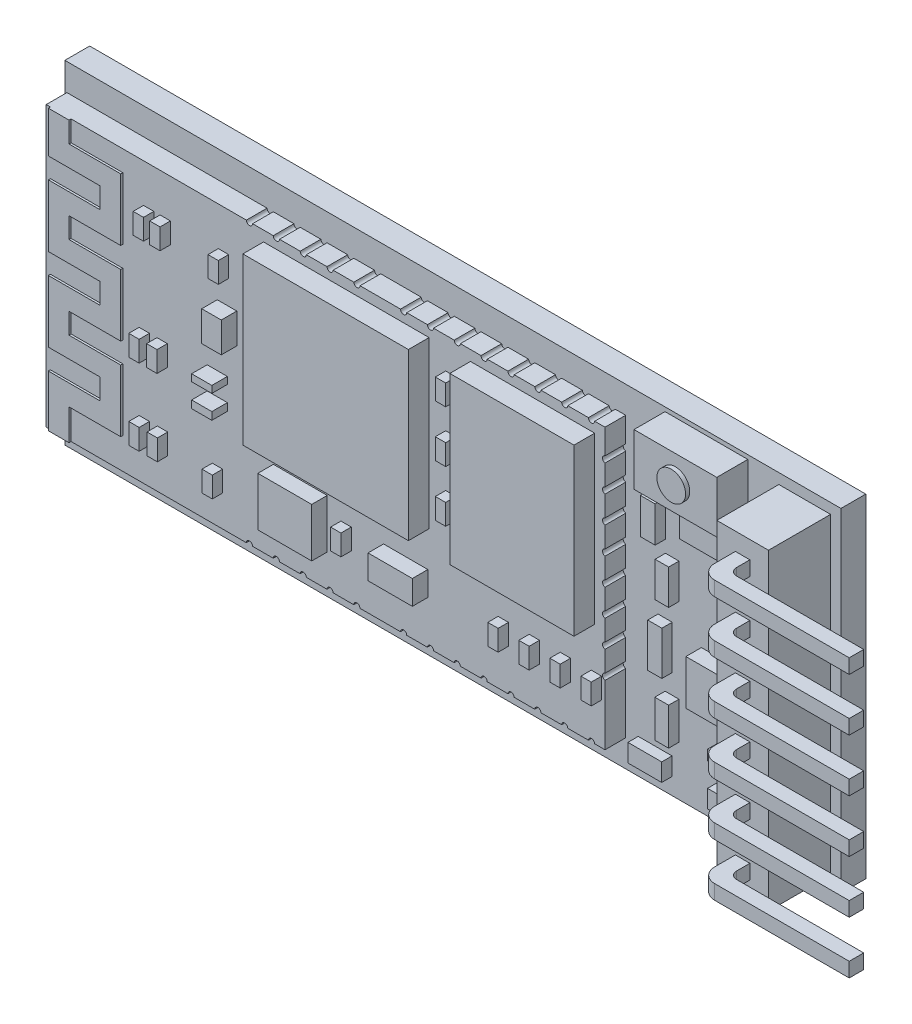
from build123d import *

# Parameters (mm, degrees)
IZIM2_W                      = 37.5
IZIM2_H                      = 16.1
Y_KSEKLIK_EKSTR_ZYON1_DEPTH  = 1.2
IZIM5_W                      = 2.5
IZIM5_H                      = 15.1
Y_KSEKLIK_EKSTR_ZYON2_DEPTH  = 3
IZIM14_W                     = 27
IZIM14_H                     = 13.5
Y_KSEKLIK_EKSTR_ZYON10_DEPTH = 1
Y_KSEKLIK_EKSTR_ZYON11_DEPTH = 0.1
IZIM16_W                     = 4
IZIM16_H                     = 2.5
Y_KSEKLIK_EKSTR_ZYON12_DEPTH = 1.5
IZIM17_R                     = 0.693604575
Y_KSEKLIK_EKSTR_ZYON13_DEPTH = 0.2
IZIM18_W                     = 6
IZIM18_H                     = 8
IZIM18_W_2                   = 8
Y_KSEKLIK_EKSTR_ZYON14_DEPTH = 1
IZIM19_W                     = 0.5
IZIM19_H                     = 1
Y_KSEKLIK_EKSTR_ZYON15_DEPTH = 0.5
IZIM22_W                     = 0.5
IZIM22_H                     = 1
Y_KSEKLIK_EKSTR_ZYON17_DEPTH = 0.5
IZIM23_W                     = 2.602430281
IZIM23_H                     = 2.367545487
IZIM23_W_2                   = 2.141321068
IZIM23_H_2                   = 1.16646021
IZIM23_W_3                   = 0.976073465
IZIM23_H_3                   = 0.365909355
IZIM23_H_4                   = 0.334632026
IZIM23_W_4                   = 0.943360629
IZIM23_H_5                   = 1.46024084
Y_KSEKLIK_EKSTR_ZYON18_DEPTH = 0.75
IZIM24_W                     = 2.706810909
IZIM24_H                     = 1.742911909
IZIM24_W_2                   = 0.716474489
IZIM24_H_2                   = 1.726632447
IZIM24_W_3                   = 0.652791749
IZIM24_H_3                   = 1.693765047
IZIM24_W_4                   = 0.684633119
IZIM24_H_4                   = 2.106353334
IZIM24_W_5                   = 0.668712434
IZIM24_H_5                   = 1.80079444
IZIM24_W_6                   = 1.634021616
IZIM24_H_6                   = 0.862411809
IZIM24_W_7                   = 1.353405455
IZIM24_H_7                   = 0.499412084
IZIM24_W_8                   = 1.368285393
IZIM24_H_8                   = 0.823617913
IZIM24_H_9                   = 0.791721171
Y_KSEKLIK_EKSTR_ZYON19_DEPTH = 0.5
IZIM25_W                     = 3.051168615
IZIM25_H                     = 2.165639046
Y_KSEKLIK_EKSTR_ZYON20_DEPTH = 0.75
KES_EKSTR_ZYON1_DEPTH        = 1
KES_EKSTR_ZYON2_DEPTH        = 1
SKETCH1_W                    = 0.7
SKETCH1_H                    = 0.7
BOSS_EXTRUDE1_DEPTH          = 1.7
SKETCH2_W                    = 0.7
SKETCH2_H                    = 0.7
BOSS_EXTRUDE2_DEPTH          = 6.5
FILLET1_R                    = 0.7
FILLET2_R                    = 0.35


with BuildPart() as part:
    # Çizim2 → Yükseklik-Ekstrüzyon1 (new body)
    with BuildSketch(Plane.XY):
        with Locations((18.75, 8.05)):
            Rectangle(IZIM2_W, IZIM2_H)
    extrude(amount=Y_KSEKLIK_EKSTR_ZYON1_DEPTH)

    # Çizim5 → Yükseklik-Ekstrüzyon2 (add)
    with BuildSketch(Plane.XY.offset(1.2)):
        with Locations((35.75, 8.05)):
            Rectangle(IZIM5_W, IZIM5_H)
    extrude(amount=Y_KSEKLIK_EKSTR_ZYON2_DEPTH)

    # Çizim14 → Yükseklik-Ekstrüzyon10 (add)
    with BuildSketch(Plane.XY.offset(1.2)):
        with Locations((13.6, 8.05)):
            Rectangle(IZIM14_W, IZIM14_H)
    extrude(amount=Y_KSEKLIK_EKSTR_ZYON10_DEPTH)

    # Çizim15 → Yükseklik-Ekstrüzyon11 (add)
    with BuildSketch(Plane.XY.offset(2.2)):
        Polygon((0.3, 1.3), (0.3, 3.8), (2.8, 3.8), (2.8, 4.8), (0.3, 4.8), (0.3, 7.8), (2.8, 7.8), (2.8, 8.8), (0.3, 8.8), (0.3, 11.8), (2.8, 11.8), (2.8, 12.8), (0.3, 12.8), (0.3, 14.8), (1.3, 14.8), (1.3, 13.8), (3.8, 13.8), (3.8, 10.8), (1.3, 10.8), (1.3, 9.8), (3.8, 9.8), (3.8, 6.8), (1.3, 6.8), (1.3, 5.8), (3.8, 5.8), (3.8, 2.8), (1.3, 2.8), (1.3, 1.3), align=None)
    extrude(amount=Y_KSEKLIK_EKSTR_ZYON11_DEPTH)



with BuildPart() as body_2:
    # Çizim16 → Yükseklik-Ekstrüzyon12 (new body)
    with BuildSketch(Plane.XY.offset(1.2)):
        with Locations((31, 14.65)):
            Rectangle(IZIM16_W, IZIM16_H)
    extrude(amount=Y_KSEKLIK_EKSTR_ZYON12_DEPTH)


with BuildPart() as part_1:
    add(part.part)

    add(body_2.part)  # Yükseklik-Ekstrüzyon13 merges body 2
    # Çizim17 → Yükseklik-Ekstrüzyon13 (add)
    with BuildSketch(Plane.XY.offset(2.7)):
        with Locations((31, 14.65)):
            Circle(IZIM17_R)
    extrude(amount=Y_KSEKLIK_EKSTR_ZYON13_DEPTH)

    # Çizim18 → Yükseklik-Ekstrüzyon14 (add)
    with BuildSketch(Plane.XY.offset(2.2)):
        with Locations((23.600429337, 10.3)):
            Rectangle(IZIM18_W, IZIM18_H)
        with Locations((14.600429337, 10.3)):
            Rectangle(IZIM18_W_2, IZIM18_H)
    extrude(amount=Y_KSEKLIK_EKSTR_ZYON14_DEPTH)

    # Çizim19 → Yükseklik-Ekstrüzyon15 (add)
    with BuildSketch(Plane.XY.offset(2.2)):
        with Locations((5.05, 12.430030241)):
            Rectangle(IZIM19_W, IZIM19_H)
        with Locations((5.85, 12.430030241)):
            Rectangle(IZIM19_W, IZIM19_H)
        with Locations((8.665669621, 12.430030241)):
            Rectangle(IZIM19_W, IZIM19_H)
    extrude(amount=Y_KSEKLIK_EKSTR_ZYON15_DEPTH)

    # Çizim22 → Yükseklik-Ekstrüzyon17 (add)
    with BuildSketch(Plane.XY.offset(2.2)):
        with Locations((4.838962256, 7.221997086)):
            Rectangle(IZIM22_W, IZIM22_H)
        with Locations((5.701638758, 7.221997086)):
            Rectangle(IZIM22_W, IZIM22_H)
        with Locations((4.838818901, 3.533540421)):
            Rectangle(IZIM22_W, IZIM22_H)
        with Locations((5.720100061, 3.533540421)):
            Rectangle(IZIM22_W, IZIM22_H)
        with Locations((8.374321984, 3.306212795)):
            Rectangle(IZIM22_W, IZIM22_H)
        with Locations((19.650429337, 12.8)):
            Rectangle(IZIM22_W, IZIM22_H)
        with Locations((19.650429337, 10.3)):
            Rectangle(IZIM22_W, IZIM22_H)
        with Locations((19.650429337, 7.8)):
            Rectangle(IZIM22_W, IZIM22_H)
        with Locations((26.685091813, 3.8)):
            Rectangle(IZIM22_W, IZIM22_H)
        with Locations((25.185091813, 3.8)):
            Rectangle(IZIM22_W, IZIM22_H)
        with Locations((23.685091813, 3.8)):
            Rectangle(IZIM22_W, IZIM22_H)
        with Locations((22.185091813, 3.8)):
            Rectangle(IZIM22_W, IZIM22_H)
        with Locations((14.590448244, 3.990810695)):
            Rectangle(IZIM22_W, IZIM22_H)
    extrude(amount=Y_KSEKLIK_EKSTR_ZYON17_DEPTH)

    # Çizim23 → Yükseklik-Ekstrüzyon18 (add)
    with BuildSketch(Plane.XY.offset(2.2)):
        with Locations((12.376318164, 4.047967675)):
            Rectangle(IZIM23_W, IZIM23_H)
        with Locations((17.469520012, 3.979476737)):
            Rectangle(IZIM23_W_2, IZIM23_H_2)
        with Locations((8.364147087, 6.520171395)):
            Rectangle(IZIM23_W_3, IZIM23_H_3)
        with Locations((8.364147087, 7.631045899)):
            Rectangle(IZIM23_W_3, IZIM23_H_4)
        with Locations((8.835827401, 10.033036523)):
            Rectangle(IZIM23_W_4, IZIM23_H_5)
    extrude(amount=Y_KSEKLIK_EKSTR_ZYON18_DEPTH)

    # Çizim24 → Yükseklik-Ekstrüzyon19 (add)
    with BuildSketch(Plane.XY.offset(1.2)):
        with Locations((31.553494099, 12.29905928)):
            Rectangle(IZIM24_W, IZIM24_H)
        with Locations((28.662605916, 11.435743057)):
            Rectangle(IZIM24_W_2, IZIM24_H_2)
        with Locations((29.347239034, 9.137191125)):
            Rectangle(IZIM24_W_3, IZIM24_H_3)
        with Locations((29.004922476, 6.207999371)):
            Rectangle(IZIM24_W_4, IZIM24_H_4)
        with Locations((29.339278692, 3.303381049)):
            Rectangle(IZIM24_W_5, IZIM24_H_5)
        with Locations((28.522267884, 1.231924795)):
            Rectangle(IZIM24_W_6, IZIM24_H_6)
        with Locations((32.230196826, 1.231924795)):
            Rectangle(IZIM24_W_7, IZIM24_H_6)
        with Locations((32.230196826, 3.053675007)):
            Rectangle(IZIM24_W_7, IZIM24_H_7)
        with Locations((32.704361967, 10.395882605)):
            Rectangle(IZIM24_W_8, IZIM24_H_8)
        with Locations((32.704361967, 8.686169187)):
            Rectangle(IZIM24_W_8, IZIM24_H_9)
    extrude(amount=Y_KSEKLIK_EKSTR_ZYON19_DEPTH)

    # Çizim25 → Yükseklik-Ekstrüzyon20 (add)
    with BuildSketch(Plane.XY.offset(1.2)):
        with Locations((32.282514113, 5.823350592)):
            Rectangle(IZIM25_W, IZIM25_H)
    extrude(amount=Y_KSEKLIK_EKSTR_ZYON20_DEPTH)

    # Çizim27 → Kes-Ekstrüzyon1 (cut)
    with BuildSketch(Plane.XY.offset(2.2)):
        with BuildLine():
            Line((26.6, 14.8), (26.3, 14.8))
            ThreePointArc((26.3, 14.8), (26.45, 14.65), (26.6, 14.8))
        make_face()
        with BuildLine():
            Line((25.3, 14.8), (25.004468137, 14.8))
            ThreePointArc((25.004468137, 14.8), (25.152234068, 14.652234068), (25.3, 14.8))
        make_face()
        with BuildLine():
            Line((23.708936273, 14.8), (24.004468137, 14.8))
            ThreePointArc((24.004468137, 14.8), (23.856702205, 14.652234068), (23.708936273, 14.8))
        make_face()
        with BuildLine():
            Line((22.408936273, 14.8), (22.708936273, 14.8))
            ThreePointArc((22.708936273, 14.8), (22.558936273, 14.65), (22.408936273, 14.8))
        make_face()
        with BuildLine():
            Line((21.408936273, 14.8), (21.108936273, 14.8))
            ThreePointArc((21.108936273, 14.8), (21.258936273, 14.65), (21.408936273, 14.8))
        make_face()
        with BuildLine():
            Line((20.108936273, 14.8), (19.81340441, 14.8))
            ThreePointArc((19.81340441, 14.8), (19.961170341, 14.652234068), (20.108936273, 14.8))
        make_face()
        with BuildLine():
            Line((18.517872546, 14.8), (18.81340441, 14.8))
            ThreePointArc((18.81340441, 14.8), (18.665638478, 14.652234068), (18.517872546, 14.8))
        make_face()
        with BuildLine():
            Line((17.217872546, 14.8), (17.517872546, 14.8))
            ThreePointArc((17.517872546, 14.8), (17.367872546, 14.65), (17.217872546, 14.8))
        make_face()
        with BuildLine():
            Line((15.261871651, 14.8), (14.961871651, 14.8))
            ThreePointArc((14.961871651, 14.8), (15.111871651, 14.65), (15.261871651, 14.8))
        make_face()
        with BuildLine():
            Line((13.961871651, 14.8), (13.666339787, 14.8))
            ThreePointArc((13.666339787, 14.8), (13.814105719, 14.652234068), (13.961871651, 14.8))
        make_face()
        with BuildLine():
            Line((12.370807924, 14.8), (12.666339787, 14.8))
            ThreePointArc((12.666339787, 14.8), (12.518573856, 14.652234068), (12.370807924, 14.8))
        make_face()
        with BuildLine():
            Line((11.070807924, 14.8), (11.370807924, 14.8))
            ThreePointArc((11.370807924, 14.8), (11.220807924, 14.65), (11.070807924, 14.8))
        make_face()
        with BuildLine():
            Line((10.070807924, 14.8), (9.770807924, 14.8))
            ThreePointArc((9.770807924, 14.8), (9.920807924, 14.65), (10.070807924, 14.8))
        make_face()
        with BuildLine():
            Line((10.070807924, 1.3), (9.770807924, 1.3))
            ThreePointArc((9.770807924, 1.3), (9.920807924, 1.45), (10.070807924, 1.3))
        make_face()
        with BuildLine():
            Line((11.070807924, 1.3), (11.370807924, 1.3))
            ThreePointArc((11.370807924, 1.3), (11.220807924, 1.45), (11.070807924, 1.3))
        make_face()
        with BuildLine():
            Line((12.370807924, 1.3), (12.666339787, 1.3))
            ThreePointArc((12.666339787, 1.3), (12.518573856, 1.447765932), (12.370807924, 1.3))
        make_face()
        with BuildLine():
            Line((13.961871651, 1.3), (13.666339787, 1.3))
            ThreePointArc((13.666339787, 1.3), (13.814105719, 1.447765932), (13.961871651, 1.3))
        make_face()
        with BuildLine():
            Line((15.261871651, 1.3), (14.961871651, 1.3))
            ThreePointArc((14.961871651, 1.3), (15.111871651, 1.45), (15.261871651, 1.3))
        make_face()
        with BuildLine():
            Line((17.217872546, 1.3), (17.517872546, 1.3))
            ThreePointArc((17.517872546, 1.3), (17.367872546, 1.45), (17.217872546, 1.3))
        make_face()
        with BuildLine():
            Line((18.517872546, 1.3), (18.81340441, 1.3))
            ThreePointArc((18.81340441, 1.3), (18.665638478, 1.447765932), (18.517872546, 1.3))
        make_face()
        with BuildLine():
            Line((20.108936273, 1.3), (19.81340441, 1.3))
            ThreePointArc((19.81340441, 1.3), (19.961170341, 1.447765932), (20.108936273, 1.3))
        make_face()
        with BuildLine():
            Line((21.408936273, 1.3), (21.108936273, 1.3))
            ThreePointArc((21.108936273, 1.3), (21.258936273, 1.45), (21.408936273, 1.3))
        make_face()
        with BuildLine():
            Line((22.408936273, 1.3), (22.708936273, 1.3))
            ThreePointArc((22.708936273, 1.3), (22.558936273, 1.45), (22.408936273, 1.3))
        make_face()
        with BuildLine():
            Line((23.708936273, 1.3), (24.004468137, 1.3))
            ThreePointArc((24.004468137, 1.3), (23.856702205, 1.447765932), (23.708936273, 1.3))
        make_face()
        with BuildLine():
            Line((25.3, 1.3), (25.004468137, 1.3))
            ThreePointArc((25.004468137, 1.3), (25.152234068, 1.447765932), (25.3, 1.3))
        make_face()
        with BuildLine():
            Line((26.6, 1.3), (26.3, 1.3))
            ThreePointArc((26.3, 1.3), (26.45, 1.45), (26.6, 1.3))
        make_face()
    extrude(amount=-KES_EKSTR_ZYON1_DEPTH, mode=Mode.SUBTRACT)

    # Çizim28 → Kes-Ekstrüzyon2 (cut)
    with BuildSketch(Plane.XY.offset(2.2)):
        with BuildLine():
            Line((27.1, 13.300479938), (27.1, 13.599833571))
            ThreePointArc((27.1, 13.599833571), (26.978735777, 13.450156754), (27.1, 13.300479938))
        make_face()
        with BuildLine():
            Line((27.1, 12.300479938), (27.1, 12.001126305))
            ThreePointArc((27.1, 12.001126305), (26.978735777, 12.150803122), (27.1, 12.300479938))
        make_face()
        with BuildLine():
            Line((27.1, 10.701772672), (27.1, 11.001126305))
            ThreePointArc((27.1, 11.001126305), (26.978735777, 10.851449489), (27.1, 10.701772672))
        make_face()
        with BuildLine():
            Line((27.1, 9.701772672), (27.1, 9.40241904))
            ThreePointArc((27.1, 9.40241904), (26.978735777, 9.552095856), (27.1, 9.701772672))
        make_face()
        with BuildLine():
            Line((27.1, 8.103065407), (27.1, 8.40241904))
            ThreePointArc((27.1, 8.40241904), (26.978735777, 8.252742223), (27.1, 8.103065407))
        make_face()
        with BuildLine():
            Line((27.1, 7.103065407), (27.1, 6.803711774))
            ThreePointArc((27.1, 6.803711774), (26.978735777, 6.953388591), (27.1, 7.103065407))
        make_face()
        with BuildLine():
            Line((27.1, 5.504358141), (27.1, 5.803711774))
            ThreePointArc((27.1, 5.803711774), (26.978735777, 5.654034958), (27.1, 5.504358141))
        make_face()
        with BuildLine():
            Line((27.1, 4.504358141), (27.1, 4.205004509))
            ThreePointArc((27.1, 4.205004509), (26.978735777, 4.354681325), (27.1, 4.504358141))
        make_face()
    extrude(amount=-KES_EKSTR_ZYON2_DEPTH, mode=Mode.SUBTRACT)

    # Sketch1 → Boss-Extrude1 (add)
    with BuildSketch(Plane.XY.offset(4.2)):
        with Locations((35.75, 1.7)):
            Rectangle(SKETCH1_W, SKETCH1_H)
        with Locations((35.75, 4.24)):
            Rectangle(SKETCH1_W, SKETCH1_H)
        with Locations((35.75, 6.78)):
            Rectangle(SKETCH1_W, SKETCH1_H)
        with Locations((35.75, 9.32)):
            Rectangle(SKETCH1_W, SKETCH1_H)
        with Locations((35.75, 11.86)):
            Rectangle(SKETCH1_W, SKETCH1_H)
        with Locations((35.75, 14.4)):
            Rectangle(SKETCH1_W, SKETCH1_H)
    extrude(amount=BOSS_EXTRUDE1_DEPTH)

    # Sketch2 → Boss-Extrude2 (add)
    with BuildSketch(Plane(origin=(36.1, 0, 0), x_dir=(0, 0, -1), z_dir=(1, 0, 0))):
        with Locations((-5.55, 1.7)):
            Rectangle(SKETCH2_W, SKETCH2_H)
        with Locations((-5.55, 4.24)):
            Rectangle(SKETCH2_W, SKETCH2_H)
        with Locations((-5.55, 6.78)):
            Rectangle(SKETCH2_W, SKETCH2_H)
        with Locations((-5.55, 9.32)):
            Rectangle(SKETCH2_W, SKETCH2_H)
        with Locations((-5.55, 11.86)):
            Rectangle(SKETCH2_W, SKETCH2_H)
        with Locations((-5.55, 14.4)):
            Rectangle(SKETCH2_W, SKETCH2_H)
    extrude(amount=BOSS_EXTRUDE2_DEPTH)

    # Fillet1
    fillet1_edges = [part_1.edges().sort_by_distance(p)[0] for p in [
        (35.4, 1.7, 5.9),
        (35.4, 4.24, 5.9),
        (35.4, 6.78, 5.9),
        (35.4, 9.32, 5.9),
        (35.4, 11.86, 5.9),
        (35.4, 14.4, 5.9),
    ]]
    fillet(fillet1_edges, radius=FILLET1_R)

    # Fillet2
    fillet2_edges = [part_1.edges().sort_by_distance(p)[0] for p in [
        (36.1, 1.7, 5.2),
        (36.1, 4.24, 5.2),
        (36.1, 6.78, 5.2),
        (36.1, 9.32, 5.2),
        (36.1, 11.86, 5.2),
        (36.1, 14.4, 5.2),
    ]]
    fillet(fillet2_edges, radius=FILLET2_R)


solid = part_1.part
